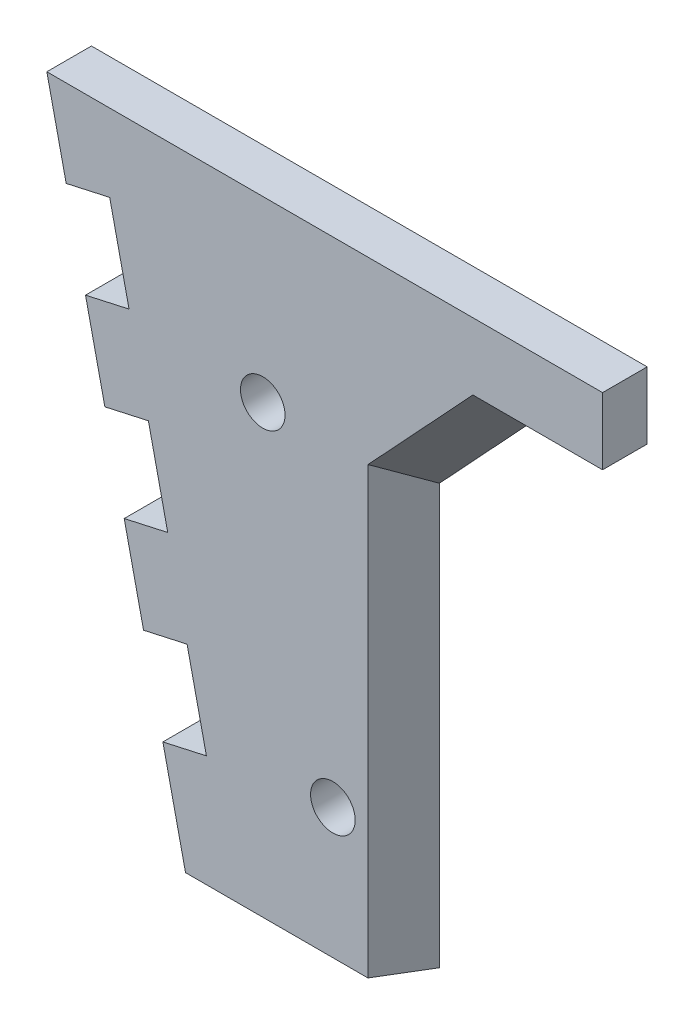
from build123d import *

# Parameters (mm, degrees)
SKETCH1_R           = 5
BOSS_EXTRUDE1_DEPTH = 10
CUT_EXTRUDE1_DEPTH  = 10
CUT_EXTRUDE2_DEPTH  = 10
CUT_EXTRUDE3_DEPTH  = 10
BOSS_EXTRUDE2_DEPTH = 15
SKETCH6_R           = 5
CUT_EXTRUDE4_DEPTH  = 10


with BuildPart() as part:
    # Sketch1 → Boss-Extrude1 (new body)
    with BuildSketch(Plane.XY):
        Polygon((-48.4220718, 40), (-17.320508076, -100), (29.627689013, -100), (29.627689013, -5.894941242), (72.353358785, 40), (54.770735732, 40), align=None)
        Circle(SKETCH1_R, mode=Mode.SUBTRACT)
    extrude(amount=BOSS_EXTRUDE1_DEPTH)

    # Sketch2 → Cut-Extrude1 (cut)
    with BuildSketch(Plane(origin=(0, 0, 0), x_dir=(-1, 0, 0), z_dir=(0, 0, -1))):
        Polygon((44.084731449, 20.475976883), (34.322719891, 22.644647058), (29.98537954, 3.120623941), (39.747391098, 0.951953766), align=None)
        Polygon((25.648039189, -16.403399176), (35.410050747, -18.572069352), (31.072710396, -38.096092469), (21.310698838, -35.927422293), align=None)
        Polygon((16.973358487, -55.45144541), (26.735370045, -57.620115586), (22.398029694, -77.144138703), (12.636018136, -74.975468528), align=None)
    extrude(amount=-CUT_EXTRUDE1_DEPTH, mode=Mode.SUBTRACT)

    # Sketch3 → Cut-Extrude2 (cut)
    with BuildSketch(Plane(origin=(11.20335331, -10.42970665, 12.614201102), x_dir=(-0.825201513, -0.359925431, 0.435311551), z_dir=(-0.564838439, 0.525833566, -0.635969023))):
        Polygon((-74.103118428, 30.827331886), (-22.327074543, -4.543132752), (-17.973959037, 1.829050982), (-4.444119228, 21.634320346), (-66.914441787, 64.310511288), (-84.797397101, 38.133058189), align=None)
    extrude(amount=-CUT_EXTRUDE2_DEPTH, mode=Mode.SUBTRACT)

    # Sketch4 → Cut-Extrude3 (cut)
    with BuildSketch(Plane(origin=(21.723952902, 0, 13.103449585), x_dir=(-0.516496434, 0, 0.85628934), z_dir=(-0.85628934, 0, -0.516496434))):
        Polygon((-3.624300151, -0.279668559), (-15.302595712, -5.894941242), (-15.302595712, -100), (-3.624300151, -100), align=None)
    extrude(amount=-CUT_EXTRUDE3_DEPTH, mode=Mode.SUBTRACT)

    # Sketch5 → Boss-Extrude2 (add)
    with BuildSketch(Plane(origin=(0, 40, 0), x_dir=(1, 0, 0), z_dir=(0, 1, 0))):
        Polygon((72.353358785, 0), (76.20595319, 0), (76.20595319, -10), (61.094050297, -10), (39.843773505, -10), (39.843773505, 0), (61.094050297, 0), align=None)
    extrude(amount=-BOSS_EXTRUDE2_DEPTH)

    # Sketch6 → Cut-Extrude4 (cut)
    with BuildSketch(Plane(origin=(0, 0, 0), x_dir=(-1, 0, 0), z_dir=(0, 0, -1))):
        with Locations((-15.722858772, -70.7745838)):
            Circle(SKETCH6_R)
    extrude(amount=-CUT_EXTRUDE4_DEPTH, mode=Mode.SUBTRACT)


solid = part.part
